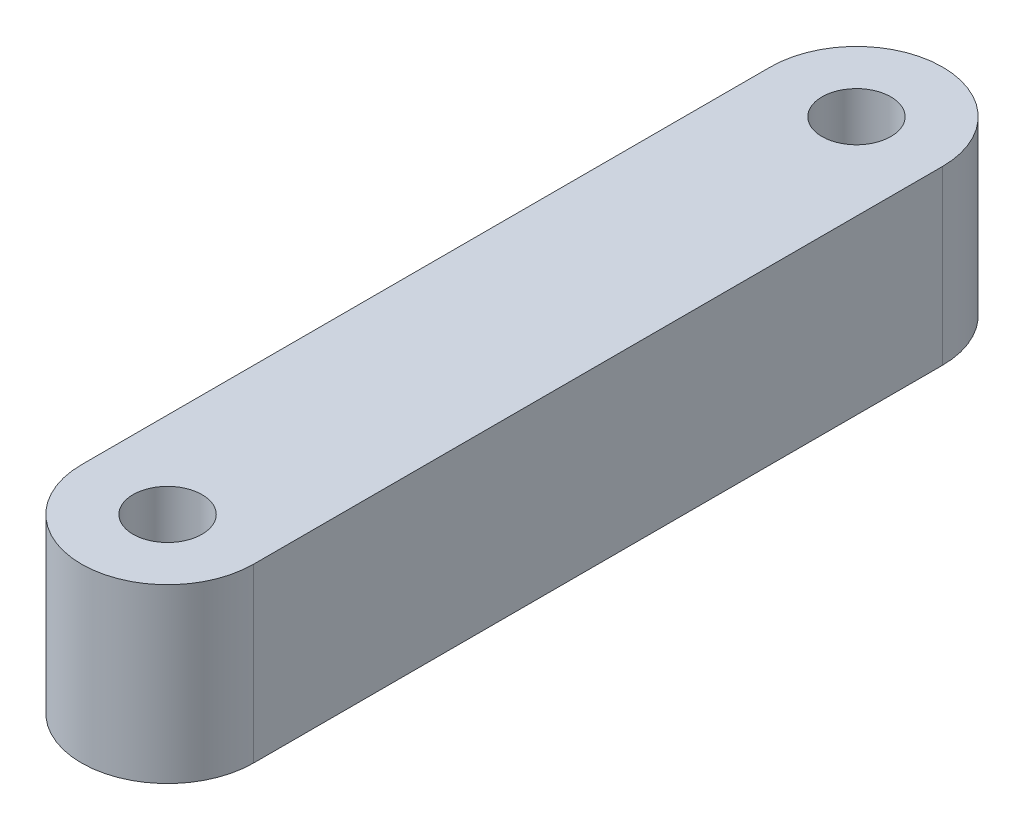
from build123d import *

# Parameters (mm, degrees)
SKETCH1_R           = 2
BOSS_EXTRUDE1_DEPTH = 10


with BuildPart() as part:
    # Sketch1 → Boss-Extrude1 (new body)
    with BuildSketch(Plane(origin=(0, 0, 0), x_dir=(1, 0, 0), z_dir=(0, 1, 0))):
        with BuildLine():
            Line((5, 0), (5, 40))
            ThreePointArc((5, 40), (0, 45), (-5, 40))
            Line((-5, 40), (-5, 0))
            ThreePointArc((-5, 0), (0, -5), (5, 0))
        make_face()
        Circle(SKETCH1_R, mode=Mode.SUBTRACT)
        with Locations((0, 40)):
            Circle(SKETCH1_R, mode=Mode.SUBTRACT)
    extrude(amount=BOSS_EXTRUDE1_DEPTH)


solid = part.part
